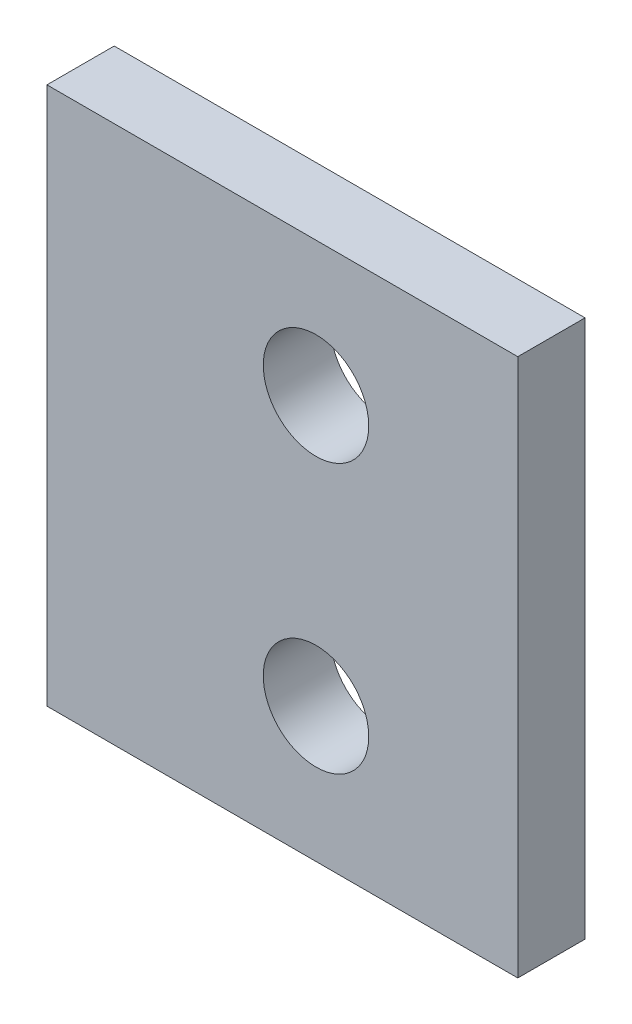
from build123d import *

# Parameters (mm, degrees)
SKETCH1_W           = 22.225
SKETCH1_H           = 25.4
SKETCH1_R           = 2.4892
BOSS_EXTRUDE1_DEPTH = 3.175


with BuildPart() as part:
    # Sketch1 → Boss-Extrude1 (new body)
    with BuildSketch(Plane.XY):
        with Locations((-14.2875, 88.9)):
            Rectangle(SKETCH1_W, SKETCH1_H)
        with Locations((-12.7, 82.55)):
            Circle(SKETCH1_R, mode=Mode.SUBTRACT)
        with Locations((-12.7, 95.25)):
            Circle(SKETCH1_R, mode=Mode.SUBTRACT)
    extrude(amount=BOSS_EXTRUDE1_DEPTH)


solid = part.part
